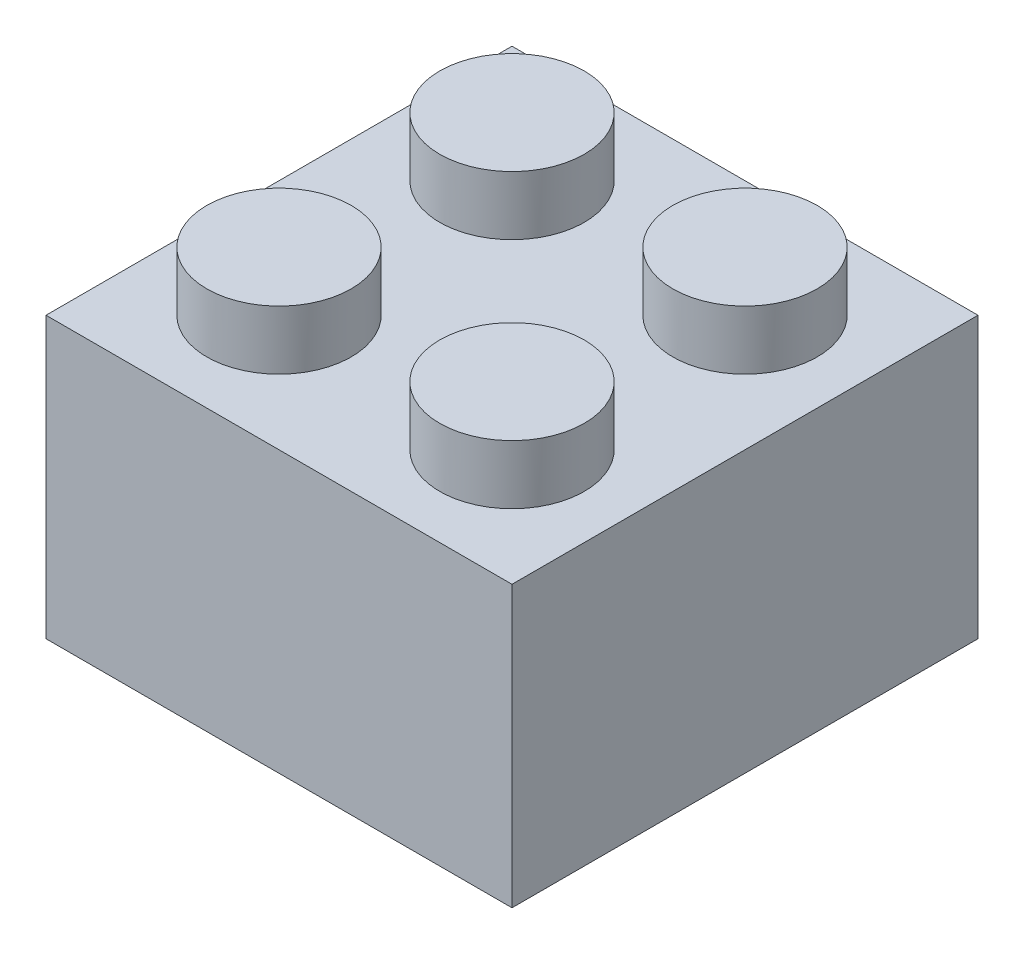
from build123d import *

# Parameters (mm, degrees)
SKETCH1_W           = 15.8
SKETCH1_H           = 15.8
BOSS_EXTRUDE1_DEPTH = 4.75
SKETCH2_R           = 2.45
BOSS_EXTRUDE2_DEPTH = 2
SKETCH4_W           = 12.8
SKETCH4_H           = 12.8
CUT_EXTRUDE1_DEPTH  = 4
SKETCH5_R           = 3.25
SKETCH5_R_2         = 2.45
BOSS_EXTRUDE3_DEPTH = 4
SKETCH7_R           = 0.25
BOSS_EXTRUDE4_DEPTH = 4


with BuildPart() as part:
    # Sketch1 → Boss-Extrude1 (new body, symmetric)
    with BuildSketch(Plane(origin=(0, 0, 0), x_dir=(1, 0, 0), z_dir=(0, 1, 0))):
        with Locations((7.9, 7.9)):
            Rectangle(SKETCH1_W, SKETCH1_H)
    extrude(amount=BOSS_EXTRUDE1_DEPTH, both=True)

    # Sketch2 → Boss-Extrude2 (add)
    with BuildSketch(Plane(origin=(0, 4.75, 0), x_dir=(1, 0, 0), z_dir=(0, 1, 0))):
        with Locations((3.95, 3.95)):
            Circle(SKETCH2_R)
        with Locations((11.85, 3.95)):
            Circle(SKETCH2_R)
        with Locations((11.85, 11.85)):
            Circle(SKETCH2_R)
        with Locations((3.95, 11.85)):
            Circle(SKETCH2_R)
    extrude(amount=BOSS_EXTRUDE2_DEPTH)

    # Sketch4 → Cut-Extrude1 (cut)
    with BuildSketch(Plane.XZ.offset(4.75)):
        with Locations((7.9, -7.9)):
            Rectangle(SKETCH4_W, SKETCH4_H)
    extrude(amount=-CUT_EXTRUDE1_DEPTH, mode=Mode.SUBTRACT)

    # Sketch5 → Boss-Extrude3 (add)
    with BuildSketch(Plane.XZ.offset(0.75)):
        with Locations((7.9, -7.9)):
            Circle(SKETCH5_R)
        with Locations((7.9, -7.9)):
            Circle(SKETCH5_R_2, mode=Mode.SUBTRACT)
    extrude(amount=BOSS_EXTRUDE3_DEPTH)

    # Sketch7 → Boss-Extrude4 (add)
    with BuildSketch(Plane.XZ.offset(0.75)):
        with Locations((3.95, -14.3)):
            Circle(SKETCH7_R)
        with Locations((1.5, -11.85)):
            Circle(SKETCH7_R)
        with Locations((1.5, -3.95)):
            Circle(SKETCH7_R)
        with Locations((3.95, -1.5)):
            Circle(SKETCH7_R)
        with Locations((11.85, -1.5)):
            Circle(SKETCH7_R)
        with Locations((14.3, -3.95)):
            Circle(SKETCH7_R)
        with Locations((14.3, -11.85)):
            Circle(SKETCH7_R)
        with Locations((11.85, -14.3)):
            Circle(SKETCH7_R)
    extrude(amount=BOSS_EXTRUDE4_DEPTH)


solid = part.part
